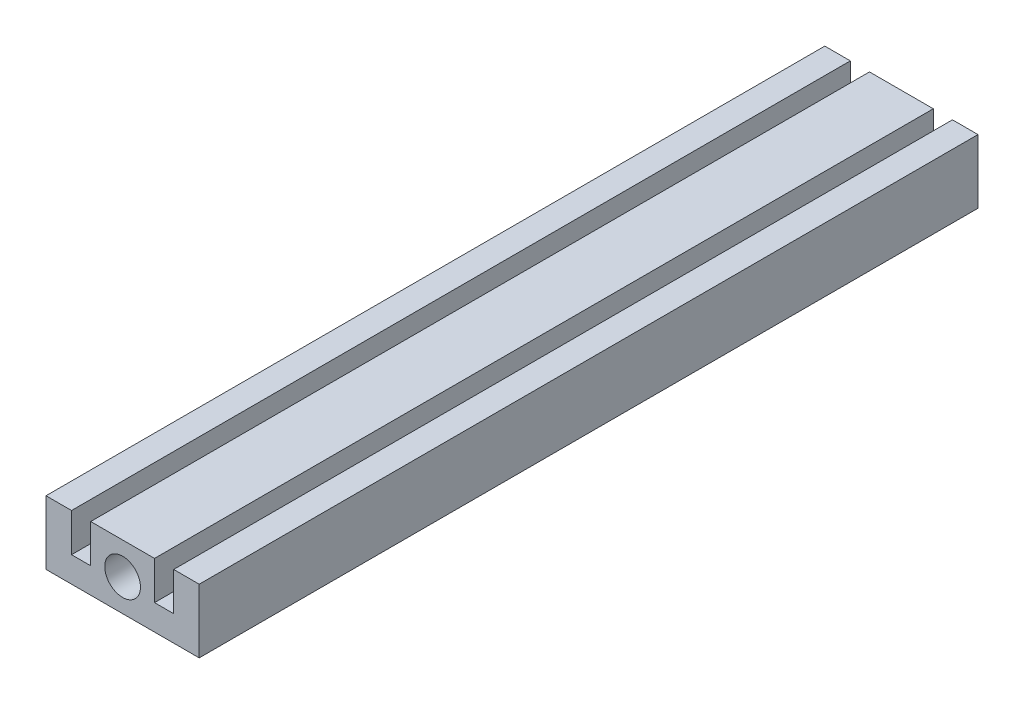
from build123d import *

# Parameters (mm, degrees)
ESQUISSE1_R        = 2.8
BOSS_EXTRU_1_DEPTH = 122


with BuildPart() as part:
    # Esquisse1 → Boss.-Extru.1 (new body)
    with BuildSketch(Plane.XY):
        Polygon((-12, 5), (-12, -5), (12, -5), (12, 5), (8, 5), (8, -1), (5, -1), (5, 5), (-5, 5), (-5, -1), (-8, -1), (-8, 5), align=None)
        Circle(ESQUISSE1_R, mode=Mode.SUBTRACT)
    extrude(amount=BOSS_EXTRU_1_DEPTH)


solid = part.part
